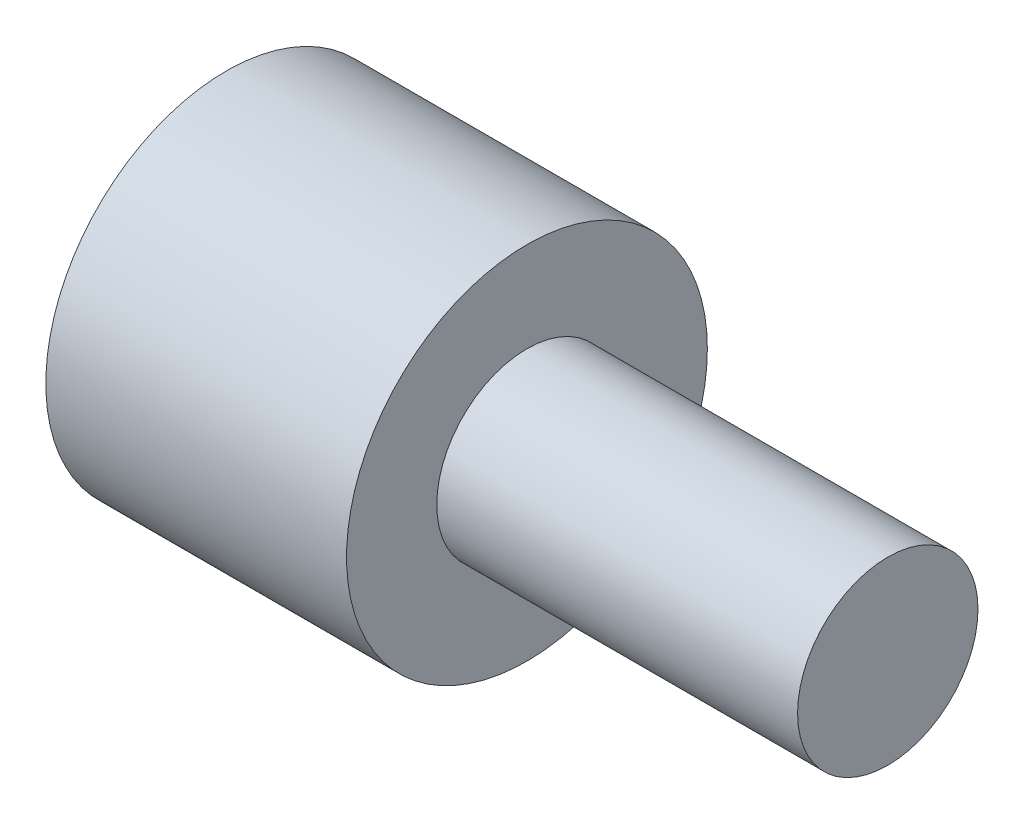
from build123d import *

# Parameters (mm, degrees)
M3_GEWINDEBOHRUNG1_D     = 2.5
M3_GEWINDEBOHRUNG1_DEPTH = 5
M3_GEWINDEBOHRUNG1_TIP   = 0.751075774


with BuildPart() as part:
    # Skizze1 → Rotation1 (revolve)
    with BuildSketch(Plane.XY):
        Polygon((0, 3), (5, 3), (5, 1.5), (11, 1.5), (11, 0), (0, 0), align=None)
    revolve(axis=Axis((11, 0, 0), (-1, 0, 0)))

    # M3 Gewindebohrung1
    with Locations(Plane.ZY):
        with Locations((0, 0)):
            Hole(M3_GEWINDEBOHRUNG1_D / 2, depth=M3_GEWINDEBOHRUNG1_DEPTH)
            with Locations((0, 0, -(M3_GEWINDEBOHRUNG1_DEPTH + M3_GEWINDEBOHRUNG1_TIP / 2))):  # 118° drill point
                Cone(0, M3_GEWINDEBOHRUNG1_D / 2, M3_GEWINDEBOHRUNG1_TIP, mode=Mode.SUBTRACT)


solid = part.part
